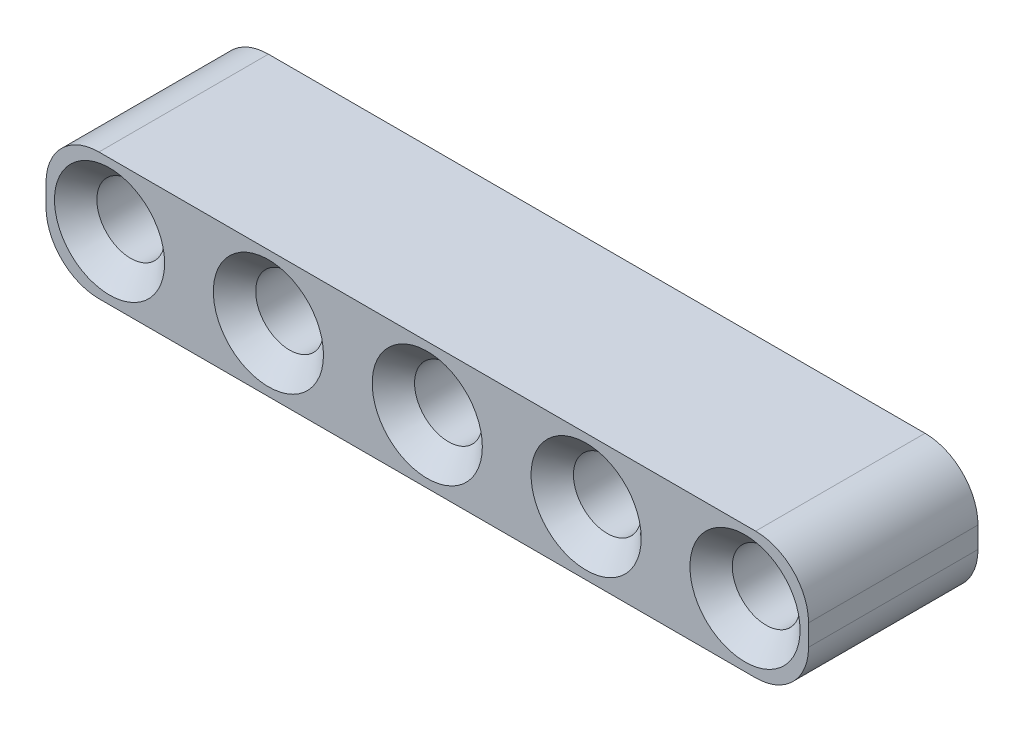
from build123d import *

# Parameters (mm, degrees)
SKETCH1_R           = 1.6
BOSS_EXTRUDE1_DEPTH = 8
CHAMFER1_SIZE       = 1


with BuildPart() as part:
    # Sketch1 → Boss-Extrude1 (new body)
    with BuildSketch(Plane.XY):
        with BuildLine():
            Line((-0.5, 3), (30.5, 3))
            ThreePointArc((30.5, 3), (32.267766953, 2.267766953), (33, 0.5))
            Line((33, 0.5), (33, -0.5))
            ThreePointArc((33, -0.5), (32.267766953, -2.267766953), (30.5, -3))
            Line((30.5, -3), (-0.5, -3))
            ThreePointArc((-0.5, -3), (-2.267766953, -2.267766953), (-3, -0.5))
            Line((-3, -0.5), (-3, 0.5))
            ThreePointArc((-3, 0.5), (-2.267766953, 2.267766953), (-0.5, 3))
        make_face()
        Circle(SKETCH1_R, mode=Mode.SUBTRACT)
        with Locations((7.5, 0)):
            Circle(SKETCH1_R, mode=Mode.SUBTRACT)
        with Locations((15, 0)):
            Circle(SKETCH1_R, mode=Mode.SUBTRACT)
        with Locations((22.5, 0)):
            Circle(SKETCH1_R, mode=Mode.SUBTRACT)
        with Locations((30, 0)):
            Circle(SKETCH1_R, mode=Mode.SUBTRACT)
    extrude(amount=BOSS_EXTRUDE1_DEPTH)

    # Chamfer1
    chamfer1_edges = [part.edges().sort_by_distance(p)[0] for p in [
        (-1.6, 0, 0),
        (-1.6, 0, 8),
        (5.9, 0, 0),
        (5.9, 0, 8),
        (13.4, 0, 0),
        (13.4, 0, 8),
        (20.9, 0, 0),
        (20.9, 0, 8),
        (28.4, 0, 0),
        (28.4, 0, 8),
    ]]
    chamfer(chamfer1_edges, length=CHAMFER1_SIZE)


solid = part.part
